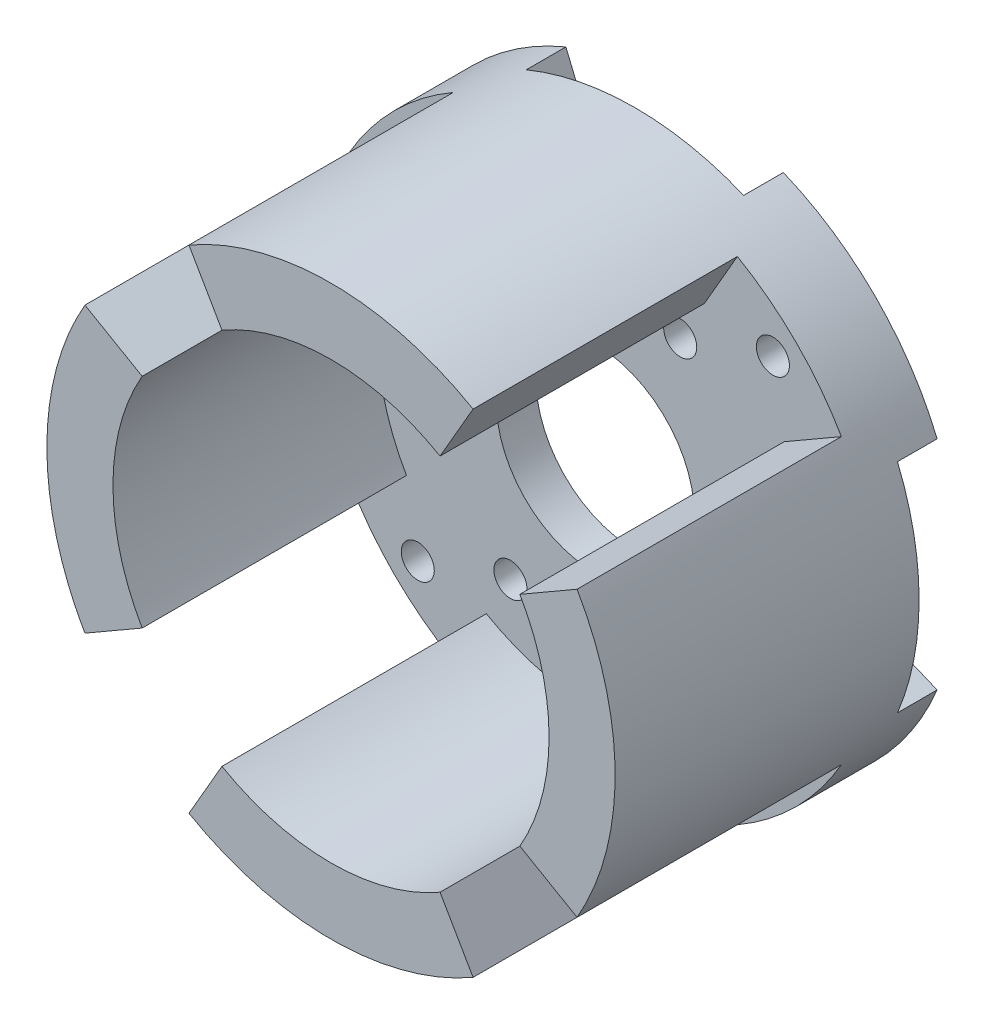
from build123d import *

# Parameters (mm, degrees)
SKETCH1_R           = 21.5
SKETCH1_R_2         = 1.25
SKETCH1_R_3         = 7.5
BOSS_EXTRUDE1_DEPTH = 3
BOSS_EXTRUDE2_START = -3
SKETCH1_3_R         = 1.25
BOSS_EXTRUDE2_DEPTH = 3
BOSS_EXTRUDE6_DEPTH = 20


with BuildPart() as part:
    # Sketch1 → Boss-Extrude1 (new body)
    with BuildSketch(Plane.XY):
        Circle(SKETCH1_R)
        with Locations((-13.435028843, 13.435028843)):
            Circle(SKETCH1_R_2, mode=Mode.SUBTRACT)
        with Locations((-6.425, -11.128426439)):
            Circle(SKETCH1_R_2, mode=Mode.SUBTRACT)
        with Locations((6.425, -11.128426439)):
            Circle(SKETCH1_R_2, mode=Mode.SUBTRACT)
        with Locations((-12.85, 0)):
            Circle(SKETCH1_R_2, mode=Mode.SUBTRACT)
        with Locations((-6.425, 11.128426439)):
            Circle(SKETCH1_R_2, mode=Mode.SUBTRACT)
        Circle(SKETCH1_R_3, mode=Mode.SUBTRACT)
        with Locations((12.85, 0)):
            Circle(SKETCH1_R_2, mode=Mode.SUBTRACT)
        with Locations((6.425, 11.128426439)):
            Circle(SKETCH1_R_2, mode=Mode.SUBTRACT)
        with Locations((13.435028843, 13.435028843)):
            Circle(SKETCH1_R_2, mode=Mode.SUBTRACT)
        with Locations((13.435028843, -13.435028843)):
            Circle(SKETCH1_R_2, mode=Mode.SUBTRACT)
        with Locations((-13.435028843, -13.435028843)):
            Circle(SKETCH1_R_2, mode=Mode.SUBTRACT)
    extrude(amount=BOSS_EXTRUDE1_DEPTH)

    # Sketch1_3 → Boss-Extrude2 (add)
    # profile 1 of 4: a face of its own
    with BuildSketch(Plane.XY.offset(BOSS_EXTRUDE2_START)):
        with BuildLine():
            ThreePointArc((-15.244012286, 6.314276634), (-11.66726189, 11.66726189), (-6.314276634, 15.244012286))
            Line((-6.314276634, 15.244012286), (-8.227693796, 19.863409949))
            ThreePointArc((-8.227693796, 19.863409949), (-15.202795796, 15.202795796), (-19.863409949, 8.227693796))
            Line((-19.863409949, 8.227693796), (-15.244012286, 6.314276634))
        make_face()
        with Locations((-13.435028843, 13.435028843)):
            Circle(SKETCH1_3_R, mode=Mode.SUBTRACT)
    # profile 2 of 4: a face of its own
    with BuildSketch(Plane.XY.offset(BOSS_EXTRUDE2_START)):
        with BuildLine():
            ThreePointArc((19.863409949, 8.227693796), (15.202795796, 15.202795796), (8.227693796, 19.863409949))
            Line((8.227693796, 19.863409949), (6.314276634, 15.244012286))
            ThreePointArc((6.314276634, 15.244012286), (11.66726189, 11.66726189), (15.244012286, 6.314276634))
            Line((15.244012286, 6.314276634), (19.863409949, 8.227693796))
        make_face()
        with Locations((13.435028843, 13.435028843)):
            Circle(SKETCH1_3_R, mode=Mode.SUBTRACT)
    # profile 3 of 4: a face of its own
    with BuildSketch(Plane.XY.offset(BOSS_EXTRUDE2_START)):
        with BuildLine():
            ThreePointArc((-6.314276634, -15.244012286), (-11.66726189, -11.66726189), (-15.244012286, -6.314276634))
            Line((-15.244012286, -6.314276634), (-19.863409949, -8.227693796))
            ThreePointArc((-19.863409949, -8.227693796), (-15.202795796, -15.202795796), (-8.227693796, -19.863409949))
            Line((-8.227693796, -19.863409949), (-6.314276634, -15.244012286))
        make_face()
        with Locations((-13.435028843, -13.435028843)):
            Circle(SKETCH1_3_R, mode=Mode.SUBTRACT)
    # profile 4 of 4: a face of its own
    with BuildSketch(Plane.XY.offset(BOSS_EXTRUDE2_START)):
        with BuildLine():
            ThreePointArc((15.244012286, -6.314276634), (11.66726189, -11.66726189), (6.314276634, -15.244012286))
            Line((6.314276634, -15.244012286), (8.227693796, -19.863409949))
            ThreePointArc((8.227693796, -19.863409949), (15.202795796, -15.202795796), (19.863409949, -8.227693796))
            Line((19.863409949, -8.227693796), (15.244012286, -6.314276634))
        make_face()
        with Locations((13.435028843, -13.435028843)):
            Circle(SKETCH1_3_R, mode=Mode.SUBTRACT)
    extrude(amount=BOSS_EXTRUDE2_DEPTH)

    # Sketch7 → Boss-Extrude6 (add)
    with BuildSketch(Plane.XY.offset(3)):
        with BuildLine():
            ThreePointArc((-14.289419162, -8.25), (-16.5, 0), (-14.289419162, 8.25))
            Line((-14.289419162, 8.25), (-18.619546181, 10.75))
            ThreePointArc((-18.619546181, 10.75), (-21.5, 0), (-18.619546181, -10.75))
            Line((-18.619546181, -10.75), (-14.289419162, -8.25))
        make_face()
        with BuildLine():
            ThreePointArc((10.75, 18.619546181), (0, 21.5), (-10.75, 18.619546181))
            Line((-10.75, 18.619546181), (-8.25, 14.289419162))
            ThreePointArc((-8.25, 14.289419162), (0, 16.5), (8.25, 14.289419162))
            Line((8.25, 14.289419162), (10.75, 18.619546181))
        make_face()
        with BuildLine():
            Line((-8.25, -14.289419162), (-10.75, -18.619546181))
            ThreePointArc((-10.75, -18.619546181), (0, -21.5), (10.75, -18.619546181))
            Line((10.75, -18.619546181), (8.25, -14.289419162))
            ThreePointArc((8.25, -14.289419162), (0, -16.5), (-8.25, -14.289419162))
        make_face()
        with BuildLine():
            ThreePointArc((18.619546181, -10.75), (21.5, 0), (18.619546181, 10.75))
            Line((18.619546181, 10.75), (14.289419162, 8.25))
            ThreePointArc((14.289419162, 8.25), (16.5, 0), (14.289419162, -8.25))
            Line((14.289419162, -8.25), (18.619546181, -10.75))
        make_face()
    extrude(amount=BOSS_EXTRUDE6_DEPTH)


solid = part.part
